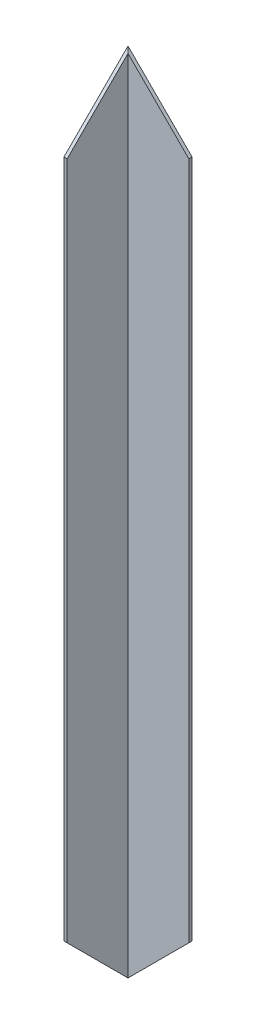
from build123d import *

# Parameters (mm, degrees)
BOSS_EXTRU_1_DEPTH      = 504
ENL_V_MAT_EXTRU_1_DEPTH = 590
ENL_V_MAT_EXTRU_2_DEPTH = 590
ENL_V_MAT_EXTRU_3_DEPTH = 41
ENL_V_MAT_EXTRU_4_DEPTH = 41


with BuildPart() as part:
    # Esquisse1 → Boss.-Extru.1 (new body)
    with BuildSketch(Plane(origin=(0, 0, 0), x_dir=(1, 0, 0), z_dir=(0, 1, 0))):
        Polygon((-20, 20.113636364), (20, 20.113636364), (20, 18.113636364), (-18, 18.113636364), (-18, -19.886363636), (-20, -19.886363636), align=None)
    extrude(amount=BOSS_EXTRU_1_DEPTH)

    # Esquisse2 → Enlèv. mat.-Extru.1 (cut)
    with BuildSketch(Plane(origin=(0, 0, -20.113636364), x_dir=(-1, 0, 0), z_dir=(0, 0, -1))):
        Polygon((20, 0), (-20, 40), (-20, 0), align=None)
    extrude(amount=-ENL_V_MAT_EXTRU_1_DEPTH, mode=Mode.SUBTRACT)

    # Esquisse3 → Enlèv. mat.-Extru.2 (cut)
    with BuildSketch(Plane.ZY.offset(20)):
        Polygon((-20.113636364, 0), (19.886363636, 40), (19.886363636, 0), align=None)
    extrude(amount=-ENL_V_MAT_EXTRU_2_DEPTH, mode=Mode.SUBTRACT)

    # Esquisse4 → Enlèv. mat.-Extru.3 (cut, through all)
    with BuildSketch(Plane.ZY.offset(20)):
        Polygon((-20.113636364, 504), (19.886363636, 464), (19.886363636, 504), align=None)
    extrude(amount=-ENL_V_MAT_EXTRU_3_DEPTH, mode=Mode.SUBTRACT)

    # Esquisse5 → Enlèv. mat.-Extru.4 (cut, through all)
    with BuildSketch(Plane(origin=(0, 0, -20.113636364), x_dir=(-1, 0, 0), z_dir=(0, 0, -1))):
        Polygon((20, 504), (-20, 464), (-20, 504), align=None)
    extrude(amount=-ENL_V_MAT_EXTRU_4_DEPTH, mode=Mode.SUBTRACT)


solid = part.part
